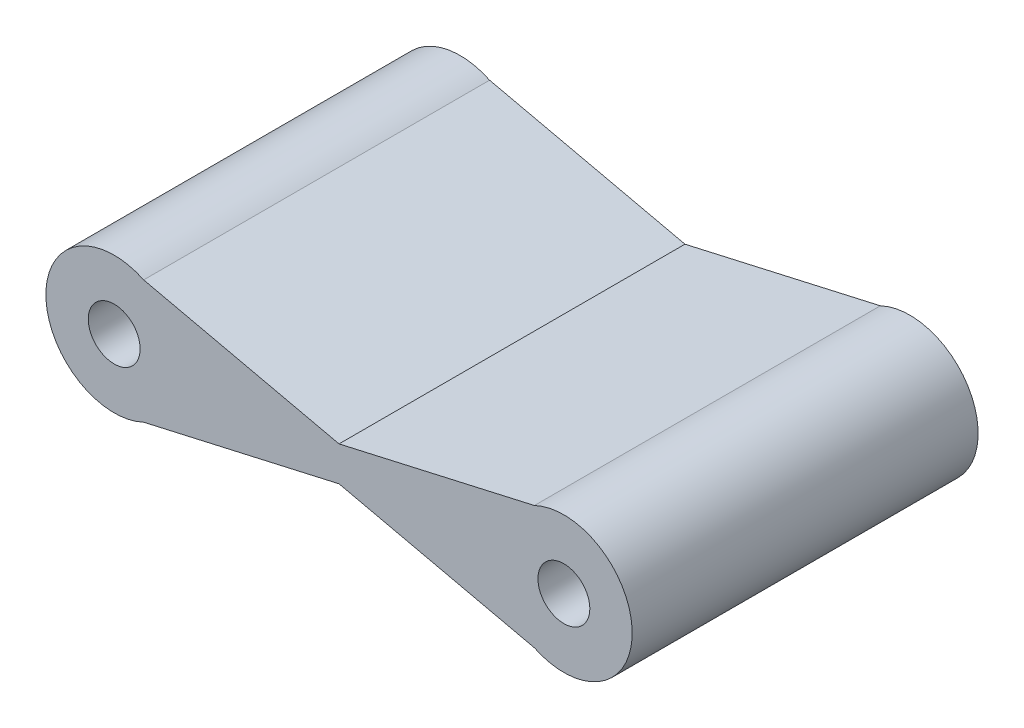
from build123d import *

# Parameters (mm, degrees)
SKETCH1_R           = 0.75
BOSS_EXTRUDE1_DEPTH = 10


with BuildPart() as part:
    # Sketch1 → Boss-Extrude1 (new body)
    with BuildSketch(Plane.XY):
        with BuildLine():
            Line((12.147549978, 2.281559418), (6.5, 1))
            Line((6.5, 1), (0.852450022, 2.281559418))
            ThreePointArc((0.852450022, 2.281559418), (-1.975, 0.5), (0.852450022, -1.281559418))
            Line((0.852450022, -1.281559418), (6.5, 0))
            Line((6.5, 0), (12.147549978, -1.281559418))
            ThreePointArc((12.147549978, -1.281559418), (14.975, 0.5), (12.147549978, 2.281559418))
        make_face()
        with Locations((0, 0.5)):
            Circle(SKETCH1_R, mode=Mode.SUBTRACT)
        with Locations((13, 0.5)):
            Circle(SKETCH1_R, mode=Mode.SUBTRACT)
    extrude(amount=BOSS_EXTRUDE1_DEPTH)


solid = part.part
